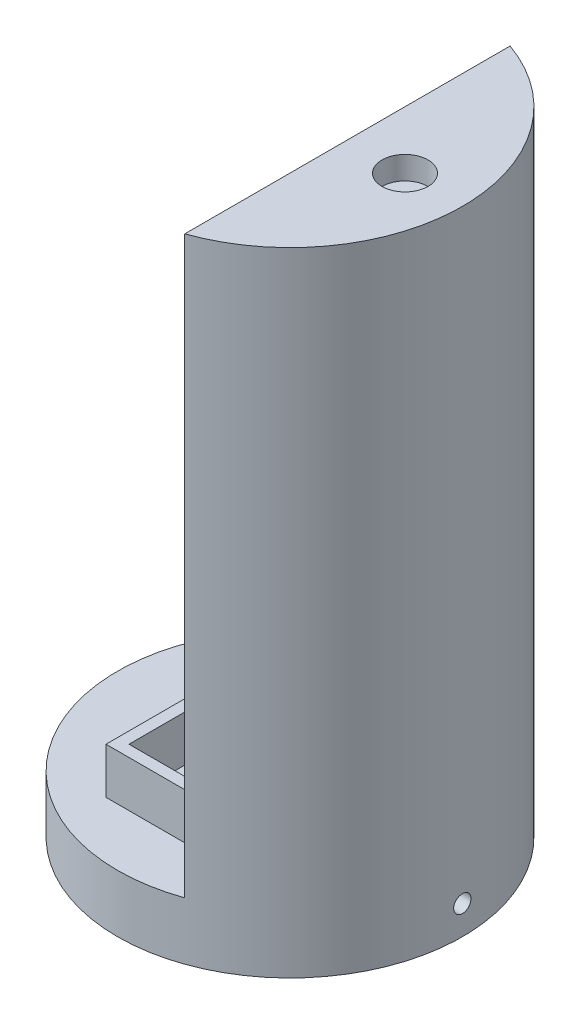
from build123d import *

# Parameters (mm, degrees)
SKETCH1_R               = 38.1
BOSS_EXTRUDE1_DEPTH     = 12.7
SKETCH2_W               = 30.48
SKETCH2_H               = 50.8
BOSS_EXTRUDE2_DEPTH     = 10.16
SKETCH3_W               = 25.4
SKETCH3_H               = 45.72
CUT_EXTRUDE1_DEPTH      = 10.16
BOSS_EXTRUDE3_DEPTH     = 127
SKETCH5_R               = 1.27
CUT_EXTRUDE2_DEPTH      = 5.08
SKETCH6_R               = 5.08
CUT_EXTRUDE3_DEPTH      = 5.08
SKETCH7_R               = 1.905
CUT_EXTRUDE4_DEPTH      = 57.658
CUT_EXTRUDE4_DEPTH_BACK = 54.61


with BuildPart() as part:
    # Sketch1 → Boss-Extrude1 (new body)
    with BuildSketch(Plane(origin=(0, 0, 0), x_dir=(1, 0, 0), z_dir=(0, 1, 0))):
        with Locations(Location((0, 0, 0), (0, 0, 270))):
            Circle(SKETCH1_R)
    extrude(amount=BOSS_EXTRUDE1_DEPTH)

    # Sketch2 → Boss-Extrude2 (add)
    with BuildSketch(Plane(origin=(0, 12.7, 0), x_dir=(1, 0, 0), z_dir=(0, 1, 0))):
        Rectangle(SKETCH2_W, SKETCH2_H)
    extrude(amount=BOSS_EXTRUDE2_DEPTH)

    # Sketch3 → Cut-Extrude1 (cut)
    with BuildSketch(Plane(origin=(0, 22.86, 0), x_dir=(1, 0, 0), z_dir=(0, 1, 0))):
        Rectangle(SKETCH3_W, SKETCH3_H)
    extrude(amount=-CUT_EXTRUDE1_DEPTH, mode=Mode.SUBTRACT)

    # Sketch4 → Boss-Extrude3 (add)
    with BuildSketch(Plane(origin=(0, 12.7, 0), x_dir=(1, 0, 0), z_dir=(0, 1, 0))):
        with BuildLine():
            Line((12.680636812, 25.4), (12.680636812, 35.927864535))
            ThreePointArc((12.680636812, 35.927864535), (38.1, 0), (12.680636812, -35.927864535))
            Line((12.680636812, -35.927864535), (12.680636812, 25.4))
        make_face()
    extrude(amount=BOSS_EXTRUDE3_DEPTH)

    # Sketch5 → Cut-Extrude2 (cut)
    with BuildSketch(Plane.ZY.offset(-12.680636812)):
        with Locations((-25.818357005, 129.781486407)):
            Circle(SKETCH5_R)
        with Locations((24.467398365, 129.781486407)):
            Circle(SKETCH5_R)
        with Locations((-25.818357005, 40.877093478)):
            Circle(SKETCH5_R)
        with Locations((24.467398365, 40.877093478)):
            Circle(SKETCH5_R)
    extrude(amount=-CUT_EXTRUDE2_DEPTH, mode=Mode.SUBTRACT)

    # Sketch6 → Cut-Extrude3 (cut)
    with BuildSketch(Plane(origin=(0, 139.7, 0), x_dir=(1, 0, 0), z_dir=(0, 1, 0))):
        with Locations(Location((25.4, 0, 0), (0, 0, 270))):
            Circle(SKETCH6_R)
    extrude(amount=-CUT_EXTRUDE3_DEPTH, mode=Mode.SUBTRACT)

    # Sketch7 → Cut-Extrude4 (cut, two sides)
    with BuildSketch(Plane(origin=(0, 0, 0), x_dir=(0, 0, -1), z_dir=(1, 0, 0))) as cut_extrude4_sk:
        with Locations(Location((0, 6.35, 0), (0, 0, 180))):
            Circle(SKETCH7_R)
    extrude(amount=CUT_EXTRUDE4_DEPTH, mode=Mode.SUBTRACT)
    extrude(cut_extrude4_sk.sketch, amount=-CUT_EXTRUDE4_DEPTH_BACK, mode=Mode.SUBTRACT)


solid = part.part
